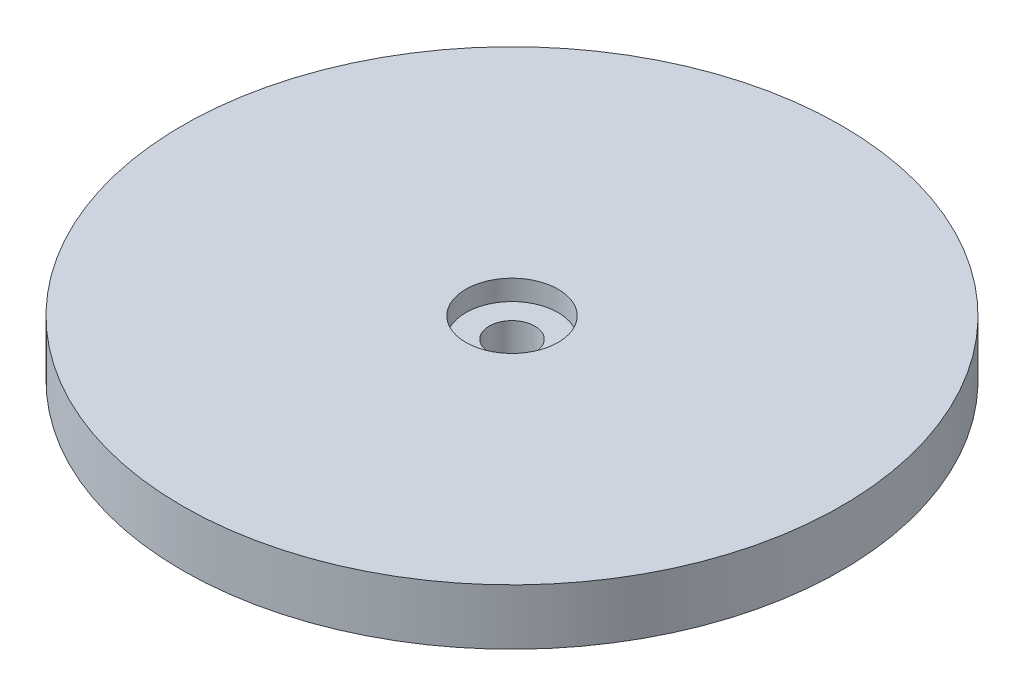
from build123d import *

# Parameters (mm, degrees)
SKETCH2_R           = 65
BOSS_EXTRUDE1_DEPTH = 11
SKETCH3_R           = 9.1
CUT_EXTRUDE2_DEPTH  = 4
SKETCH4_R           = 4.5
CUT_EXTRUDE4_DEPTH  = 20


with BuildPart() as part:
    # Sketch2 → Boss-Extrude1 (new body)
    with BuildSketch(Plane(origin=(0, 0, 0), x_dir=(1, 0, 0), z_dir=(0, 1, 0))):
        Circle(SKETCH2_R)
    extrude(amount=BOSS_EXTRUDE1_DEPTH)

    # Sketch3 → Cut-Extrude2 (cut)
    with BuildSketch(Plane(origin=(0, 11, 0), x_dir=(1, 0, 0), z_dir=(0, 1, 0))):
        Circle(SKETCH3_R)
    extrude(amount=-CUT_EXTRUDE2_DEPTH, mode=Mode.SUBTRACT)

    # Sketch4 → Cut-Extrude4 (cut)
    with BuildSketch(Plane(origin=(0, 7, 0), x_dir=(1, 0, 0), z_dir=(0, 1, 0))):
        Circle(SKETCH4_R)
    extrude(amount=-CUT_EXTRUDE4_DEPTH, mode=Mode.SUBTRACT)


solid = part.part
